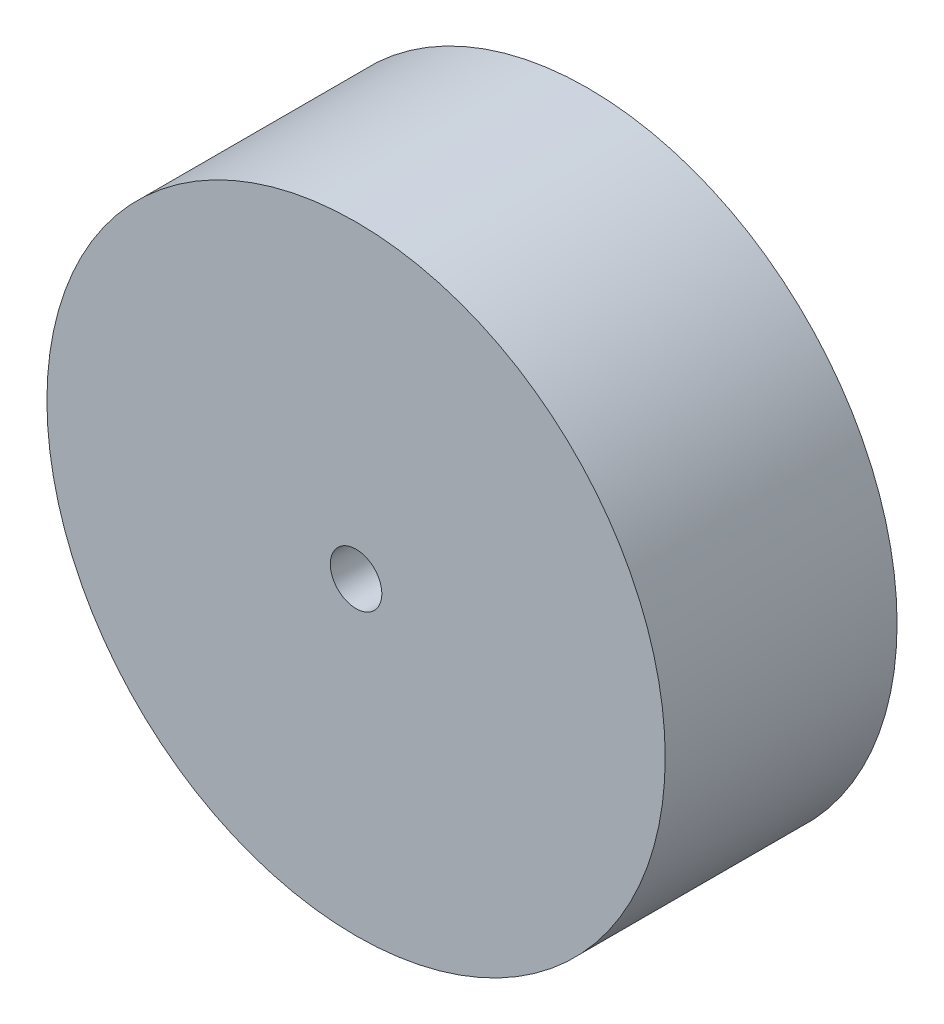
from build123d import *

# Parameters (mm, degrees)
ESQUISSE1_R             = 36
BOSS_EXTRU_1_DEPTH      = 27
ESQUISSE2_R             = 3
ENL_V_MAT_EXTRU_1_DEPTH = 27


with BuildPart() as part:
    # Esquisse1 → Boss.-Extru.1 (new body)
    with BuildSketch(Plane.XY):
        Circle(ESQUISSE1_R)
    extrude(amount=BOSS_EXTRU_1_DEPTH)

    # Esquisse2 → Enlèv. mat.-Extru.1 (cut)
    with BuildSketch(Plane.XY.offset(27)):
        Circle(ESQUISSE2_R)
    extrude(amount=-ENL_V_MAT_EXTRU_1_DEPTH, mode=Mode.SUBTRACT)


solid = part.part
